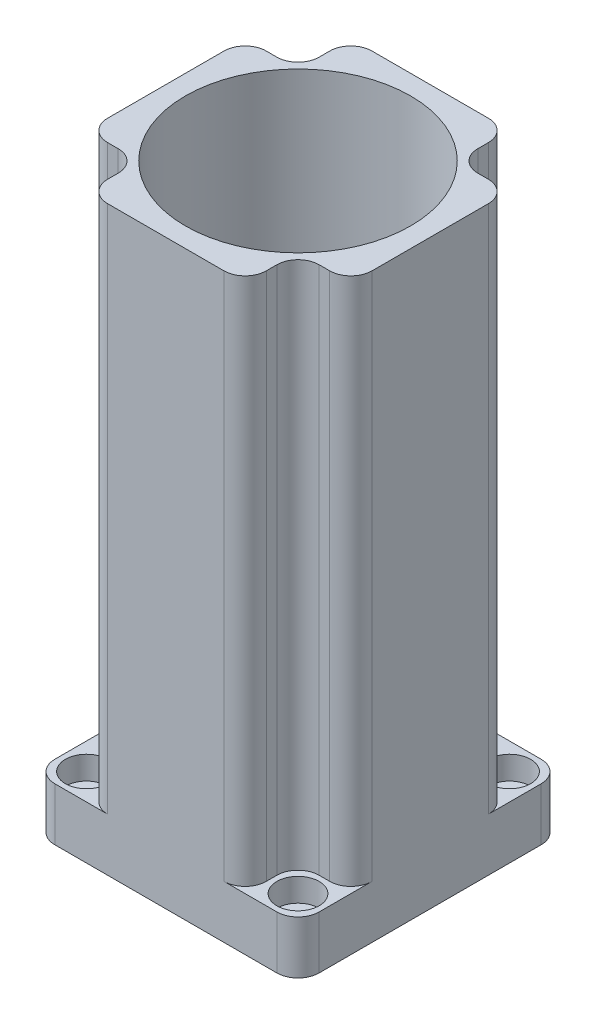
from build123d import *

# Parameters (mm, degrees)
ESQUISSE1_W                                       = 50
ESQUISSE1_H                                       = 50
ESQUISSE1_R                                       = 14.5
BOSS_EXTRU_1_DEPTH                                = 10
ESQUISSE2_R                                       = 21.3
BOSS_EXTRU_2_DEPTH                                = 100
CHAMBRAGE_POUR_VIS_SIX_PANS_CREUX_M41_D           = 4.5
CHAMBRAGE_POUR_VIS_SIX_PANS_CREUX_M41_CBORE_D     = 8
CHAMBRAGE_POUR_VIS_SIX_PANS_CREUX_M41_CBORE_DEPTH = 4.4
CHAMBRAGE_POUR_VIS_SIX_PANS_CREUX_M42_D           = 4.8
CHAMBRAGE_POUR_VIS_SIX_PANS_CREUX_M42_CBORE_D     = 8
CHAMBRAGE_POUR_VIS_SIX_PANS_CREUX_M42_CBORE_DEPTH = 4.4
CONG_1_R                                          = 4


with BuildPart() as part:
    # Esquisse1 → Boss.-Extru.1 (new body)
    with BuildSketch(Plane(origin=(0, 0, 0), x_dir=(1, 0, 0), z_dir=(0, 1, 0))):
        with Locations((25, 25)):
            Rectangle(ESQUISSE1_W, ESQUISSE1_H)
        with Locations((25, 25)):
            Circle(ESQUISSE1_R, mode=Mode.SUBTRACT)
    extrude(amount=BOSS_EXTRU_1_DEPTH)

    # Esquisse2 → Boss.-Extru.2 (add)
    with BuildSketch(Plane(origin=(0, 10, 0), x_dir=(1, 0, 0), z_dir=(0, 1, 0))):
        with BuildLine():
            Line((40, 44), (40, 46))
            ThreePointArc((40, 46), (38.828427125, 48.828427125), (36, 50))
            Line((36, 50), (14, 50))
            ThreePointArc((14, 50), (11.171572875, 48.828427125), (10, 46))
            Line((10, 46), (10, 44))
            ThreePointArc((10, 44), (8.828427125, 41.171572875), (6, 40))
            Line((6, 40), (4, 40))
            ThreePointArc((4, 40), (1.171572875, 38.828427125), (0, 36))
            Line((0, 36), (0, 14))
            ThreePointArc((0, 14), (1.171572875, 11.171572875), (4, 10))
            Line((4, 10), (6, 10))
            ThreePointArc((6, 10), (8.828427125, 8.828427125), (10, 6))
            Line((10, 6), (10, 4))
            ThreePointArc((10, 4), (11.171572875, 1.171572875), (14, 0))
            Line((14, 0), (36, 0))
            ThreePointArc((36, 0), (38.828427125, 1.171572875), (40, 4))
            Line((40, 4), (40, 6))
            ThreePointArc((40, 6), (41.171572875, 8.828427125), (44, 10))
            Line((44, 10), (46, 10))
            ThreePointArc((46, 10), (48.828427125, 11.171572875), (50, 14))
            Line((50, 14), (50, 36))
            ThreePointArc((50, 36), (48.828427125, 38.828427125), (46, 40))
            Line((46, 40), (44, 40))
            ThreePointArc((44, 40), (41.171572875, 41.171572875), (40, 44))
        make_face()
        with Locations((25, 25)):
            Circle(ESQUISSE2_R, mode=Mode.SUBTRACT)
    extrude(amount=BOSS_EXTRU_2_DEPTH)

    # Chambrage pour vis à six pans creux M41 (through all)
    with Locations(Plane(origin=(5, 10, -45), x_dir=(0, 0, 1), z_dir=(0, 1, 0))):
        with Locations((0, 0), (0, 40), (40, 40), (40, 0)):
            CounterBoreHole(CHAMBRAGE_POUR_VIS_SIX_PANS_CREUX_M41_D / 2, CHAMBRAGE_POUR_VIS_SIX_PANS_CREUX_M41_CBORE_D / 2, CHAMBRAGE_POUR_VIS_SIX_PANS_CREUX_M41_CBORE_DEPTH)

    # Chambrage pour vis à six pans creux M42 (through all)
    with Locations(Plane(origin=(25, 0, -7.5), x_dir=(0, 0, -1), z_dir=(0, -1, 0))):
        with Locations((0, 0), (17.5, 17.5), (35, 0), (17.5, -17.5)):
            CounterBoreHole(CHAMBRAGE_POUR_VIS_SIX_PANS_CREUX_M42_D / 2, CHAMBRAGE_POUR_VIS_SIX_PANS_CREUX_M42_CBORE_D / 2, CHAMBRAGE_POUR_VIS_SIX_PANS_CREUX_M42_CBORE_DEPTH)

    # Congé1
    cong_1_edges = [part.edges().sort_by_distance(p)[0] for p in [
        (0, 5, -50),
        (50, 5, -50),
        (50, 5, 0),
        (0, 5, 0),
    ]]
    fillet(cong_1_edges, radius=CONG_1_R)


solid = part.part
